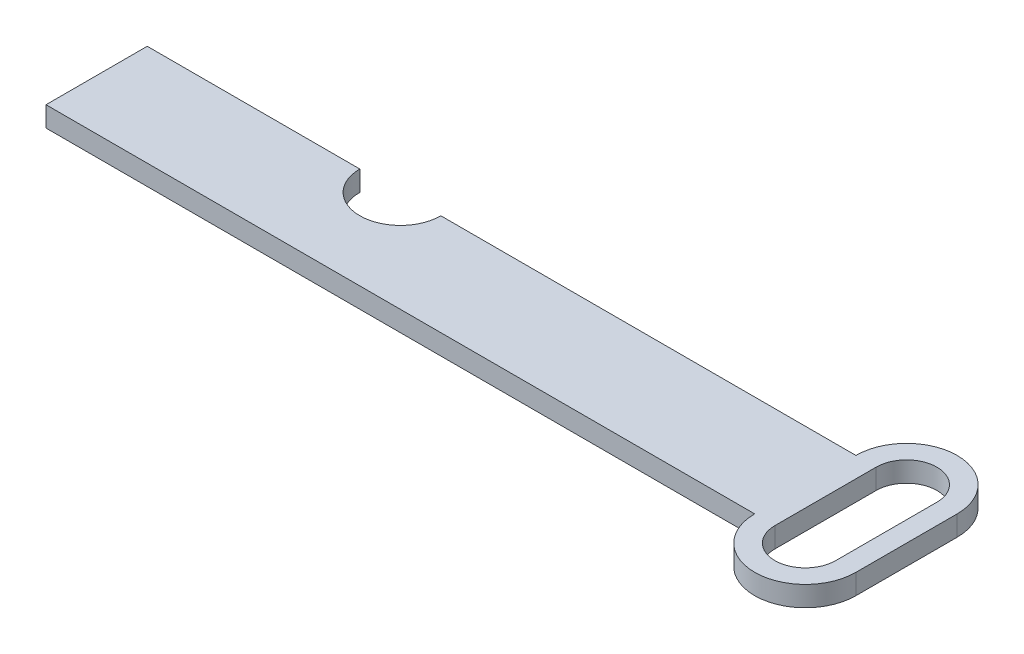
from build123d import *

# Parameters (mm, degrees)
BOSS_EXTRUDE1_DEPTH = 2
BOSS_EXTRUDE2_DEPTH = 2
CUT_EXTRUDE1_DEPTH  = 2


with BuildPart() as part:
    # Sketch1 → Boss-Extrude1 (new body)
    with BuildSketch(Plane(origin=(0, 0, 0), x_dir=(1, 0, 0), z_dir=(0, 1, 0))):
        with BuildLine():
            Line((0, 10), (0, 0))
            Line((0, 0), (70, 0))
            Line((70, 0), (70, 10))
            Line((70, 10), (29, 10))
            ThreePointArc((29, 10), (25, 6), (21, 10))
            Line((21, 10), (0, 10))
        make_face()
    extrude(amount=BOSS_EXTRUDE1_DEPTH)

    # Sketch2 → Boss-Extrude2 (add)
    with BuildSketch(Plane(origin=(0, 2, 0), x_dir=(1, 0, 0), z_dir=(0, 1, 0))):
        with BuildLine():
            Line((80, 10), (80, 0))
            ThreePointArc((80, 0), (75, -5), (70, 0))
            Line((70, 0), (70, 10))
            ThreePointArc((70, 10), (75, 15), (80, 10))
        make_face()
    extrude(amount=-BOSS_EXTRUDE2_DEPTH)

    # Sketch3 → Cut-Extrude1 (cut)
    with BuildSketch(Plane(origin=(0, 2, 0), x_dir=(1, 0, 0), z_dir=(0, 1, 0))):
        with BuildLine():
            Line((78, 10), (78, 0))
            ThreePointArc((78, 0), (75, -3), (72, 0))
            Line((72, 0), (72, 10))
            ThreePointArc((72, 10), (75, 13), (78, 10))
        make_face()
    extrude(amount=-CUT_EXTRUDE1_DEPTH, mode=Mode.SUBTRACT)


solid = part.part
